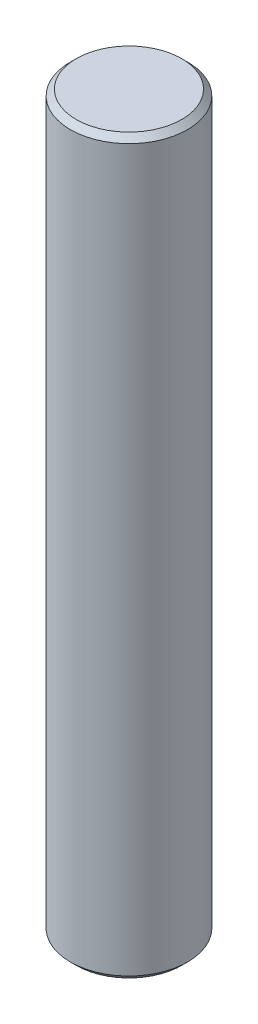
from build123d import *

# Parameters (mm, degrees)
SKETCH_1_R      = 2
EXTRUDE_1_DEPTH = 25
CHAMFER_1_SIZE  = 0.2


with BuildPart() as part:
    # 草图1 → 凸台-拉伸1 (new body)
    with BuildSketch(Plane(origin=(0, 0, 0), x_dir=(1, 0, 0), z_dir=(0, 1, 0))):
        Circle(SKETCH_1_R)
    extrude(amount=EXTRUDE_1_DEPTH)

    # 倒角1
    chamfer_1_edges = [part.edges().sort_by_distance(p)[0] for p in [
        (-2, 0, 0),
        (-2, 25, 0),
    ]]
    chamfer(chamfer_1_edges, length=CHAMFER_1_SIZE)


solid = part.part
